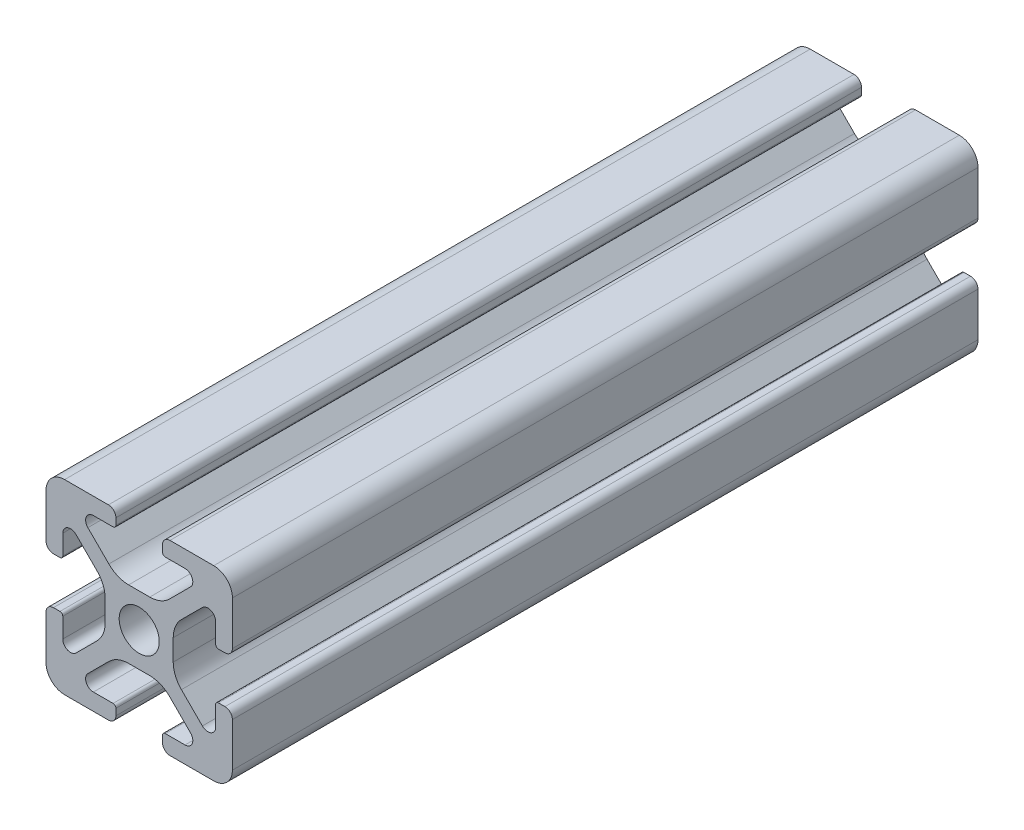
from build123d import *

# Parameters (mm, degrees)
SKETCH1_R           = 2.15
BOSS_EXTRUDE1_DEPTH = 80


with BuildPart() as part:
    # Sketch1 → Boss-Extrude1 (new body)
    with BuildSketch(Plane(origin=(0, 0, 0), x_dir=(-1, 0, 0), z_dir=(0, 0, -1))):
        with BuildLine():
            Line((-12.499999997, 0.800000003), (-12.499999998, 1.500000003))
            ThreePointArc((-12.499999998, 1.500000003), (-12.587867964, 1.712132039), (-12.8, 1.800000005))
            Line((-12.8, 1.800000005), (-14.9175884, 1.800000005))
            ThreePointArc((-14.9175884, 1.800000005), (-15.686636445, 2.313861481), (-15.506192291, 3.221015502))
            Line((-15.506192291, 3.221015502), (-13.255887451, 5.471320342))
            ThreePointArc((-13.255887451, 5.471320342), (-12.282617405, 6.121638595), (-11.134567109, 6.349999998))
            Line((-11.134567109, 6.349999998), (-8.865432906, 6.349999998))
            ThreePointArc((-8.865432906, 6.349999998), (-7.717382611, 6.121638596), (-6.744112565, 5.471320342))
            Line((-6.744112565, 5.471320342), (-4.493807727, 3.221015504))
            ThreePointArc((-4.493807727, 3.221015504), (-4.313363573, 2.313861481), (-5.082411619, 1.800000005))
            Line((-5.082411619, 1.800000005), (-7.20000001, 1.800000005))
            ThreePointArc((-7.20000001, 1.800000005), (-7.412132045, 1.71213204), (-7.50000001, 1.500000005))
            Line((-7.50000001, 1.500000005), (-7.50000001, 0.8))
            ThreePointArc((-7.50000001, 0.8), (-7.265685435, 0.234314575), (-6.70000001, 0))
            Line((-6.70000001, 0), (-2, 0))
            ThreePointArc((-2, 0), (-0.585786438, 0.585786438), (0, 2))
            Line((0, 2), (0, 6.699999998))
            ThreePointArc((0, 6.699999998), (-0.234314576, 7.265685424), (-0.800000003, 7.5))
            Line((-0.800000003, 7.5), (-1.500000007, 7.5))
            ThreePointArc((-1.500000007, 7.5), (-1.712132044, 7.412132033), (-1.80000001, 7.199999997))
            Line((-1.80000001, 7.199999997), (-1.80000001, 5.082411604))
            ThreePointArc((-1.80000001, 5.082411604), (-2.313861485, 4.313363559), (-3.221015507, 4.493807713))
            Line((-3.221015507, 4.493807713), (-5.471320347, 6.744112553))
            ThreePointArc((-5.471320347, 6.744112553), (-6.1216386, 7.717382599), (-6.350000003, 8.865432896))
            Line((-6.350000003, 8.865432896), (-6.350000003, 11.134567105))
            ThreePointArc((-6.350000003, 11.134567105), (-6.121638601, 12.2826174), (-5.471320347, 13.255887446))
            Line((-5.471320347, 13.255887446), (-3.221015511, 15.506192282))
            ThreePointArc((-3.221015511, 15.506192282), (-2.313861487, 15.686636436), (-1.80000001, 14.917588389))
            Line((-1.80000001, 14.917588389), (-1.80000001, 12.799999998))
            ThreePointArc((-1.80000001, 12.799999998), (-1.712132045, 12.587867963), (-1.50000001, 12.499999997))
            Line((-1.50000001, 12.499999997), (-0.8, 12.499999997))
            ThreePointArc((-0.8, 12.499999997), (-0.234314575, 12.734314573), (0, 13.299999998))
            Line((0, 13.299999998), (0, 18))
            ThreePointArc((0, 18), (-0.585786438, 19.414213562), (-2, 20))
            Line((-2, 20), (-6.700000008, 20))
            ThreePointArc((-6.700000008, 20), (-7.265685435, 19.765685424), (-7.50000001, 19.199999998))
            Line((-7.50000001, 19.199999998), (-7.50000001, 18.500000005))
            ThreePointArc((-7.50000001, 18.500000005), (-7.412132044, 18.287867969), (-7.200000008, 18.200000003))
            Line((-7.200000008, 18.200000003), (-5.082411595, 18.200000003))
            ThreePointArc((-5.082411595, 18.200000003), (-4.313363547, 17.686138525), (-4.493807702, 16.7789845))
            Line((-4.493807702, 16.7789845), (-6.744112543, 14.528679659))
            ThreePointArc((-6.744112543, 14.528679659), (-7.717382589, 13.878361405), (-8.865432885, 13.650000003))
            Line((-8.865432885, 13.650000003), (-11.134567111, 13.650000003))
            ThreePointArc((-11.134567111, 13.650000003), (-12.282617406, 13.878361405), (-13.255887452, 14.528679658))
            Line((-13.255887452, 14.528679658), (-15.506192292, 16.778984498))
            ThreePointArc((-15.506192292, 16.778984498), (-15.686636447, 17.686138525), (-14.917588397, 18.200000002))
            Line((-14.917588397, 18.200000002), (-12.799999998, 18.200000003))
            ThreePointArc((-12.799999998, 18.200000003), (-12.587867963, 18.287867968), (-12.499999997, 18.500000002))
            Line((-12.499999997, 18.500000002), (-12.499999997, 19.2))
            ThreePointArc((-12.499999997, 19.2), (-12.734314573, 19.765685425), (-13.299999998, 20))
            Line((-13.299999998, 20), (-18, 20))
            ThreePointArc((-18, 20), (-19.414213562, 19.414213562), (-20, 18))
            Line((-20, 18), (-20, 13.3))
            ThreePointArc((-20, 13.3), (-19.765685424, 12.734314573), (-19.199999998, 12.499999997))
            Line((-19.199999998, 12.499999997), (-18.500000003, 12.499999997))
            ThreePointArc((-18.500000003, 12.499999997), (-18.287867967, 12.587867964), (-18.2, 12.8))
            Line((-18.2, 12.8), (-18.2, 14.91758839))
            ThreePointArc((-18.2, 14.91758839), (-17.686138525, 15.686636435), (-16.778984504, 15.506192281))
            Line((-16.778984504, 15.506192281), (-14.528679657, 13.255887434))
            ThreePointArc((-14.528679657, 13.255887434), (-13.878361403, 12.282617388), (-13.65, 11.134567091))
            Line((-13.65, 11.134567091), (-13.65, 8.865432887))
            ThreePointArc((-13.65, 8.865432887), (-13.878361403, 7.717382591), (-14.528679656, 6.744112546))
            Line((-14.528679656, 6.744112546), (-16.778984496, 4.493807706))
            ThreePointArc((-16.778984496, 4.493807706), (-17.686138522, 4.313363551), (-18.2, 5.0824116))
            Line((-18.2, 5.0824116), (-18.2, 7.2))
            ThreePointArc((-18.2, 7.2), (-18.287867966, 7.412132034), (-18.5, 7.5))
            Line((-18.5, 7.5), (-19.2, 7.5))
            ThreePointArc((-19.2, 7.5), (-19.765685425, 7.265685425), (-20, 6.7))
            Line((-20, 6.7), (-20, 2))
            ThreePointArc((-20, 2), (-19.414213562, 0.585786438), (-18, 0))
            Line((-18, 0), (-13.3, 0))
            ThreePointArc((-13.3, 0), (-12.734314573, 0.234314576), (-12.499999997, 0.800000003))
        make_face()
        with Locations((-10, 10)):
            Circle(SKETCH1_R, mode=Mode.SUBTRACT)
    extrude(amount=-BOSS_EXTRUDE1_DEPTH)


solid = part.part
